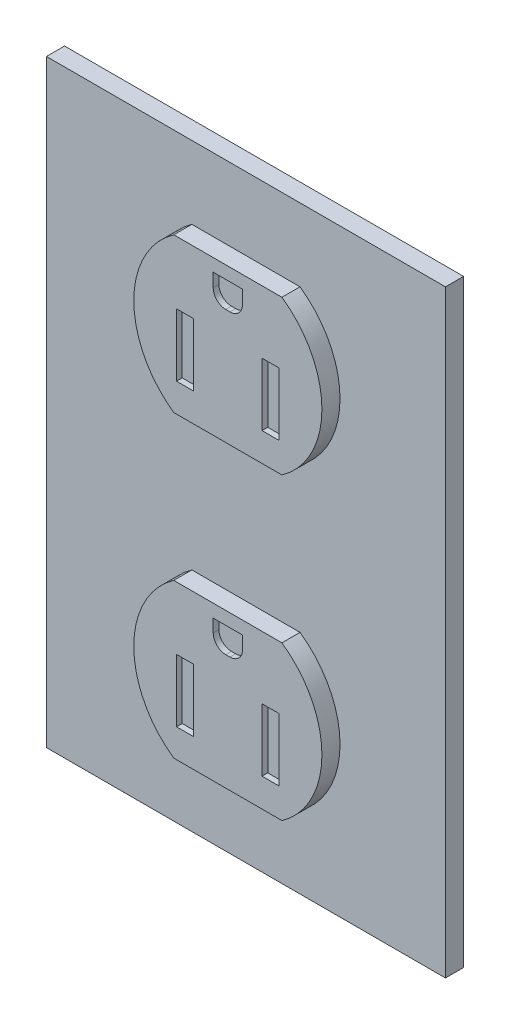
from build123d import *

# Parameters (mm, degrees)
CROQUIS1_W              = 70
CROQUIS1_H              = 105
SALIENTE_EXTRUIR1_DEPTH = 3.175
CROQUIS2_R              = 16.5
SALIENTE_EXTRUIR2_DEPTH = 3.175
CROQUIS3_W              = 26
CROQUIS3_H              = 6
CORTAR_EXTRUIR1_DEPTH   = 3.175
CROQUIS4_W              = 3
CROQUIS4_H              = 11
CORTAR_EXTRUIR2_DEPTH   = 1


with BuildPart() as part:
    # Croquis1 → Saliente-Extruir1 (new body)
    with BuildSketch(Plane.XY):
        with Locations((35, -52.5)):
            Rectangle(CROQUIS1_W, CROQUIS1_H)
    extrude(amount=SALIENTE_EXTRUIR1_DEPTH)

    # Croquis2 → Saliente-Extruir2 (add)
    with BuildSketch(Plane.XY.offset(3.175)):
        with Locations((35, -26.25)):
            Circle(CROQUIS2_R)
        with Locations((35, -78.75)):
            Circle(CROQUIS2_R)
    extrude(amount=SALIENTE_EXTRUIR2_DEPTH)

    # Croquis3 → Cortar-Extruir1 (cut)
    with BuildSketch(Plane.XY.offset(6.35)):
        with Locations((35, -9.75)):
            Rectangle(CROQUIS3_W, CROQUIS3_H)
        with Locations((35, -42.75)):
            Rectangle(CROQUIS3_W, CROQUIS3_H)
        with Locations((35, -62.25)):
            Rectangle(CROQUIS3_W, CROQUIS3_H)
        with Locations((35, -95.25)):
            Rectangle(CROQUIS3_W, CROQUIS3_H)
    extrude(amount=-CORTAR_EXTRUIR1_DEPTH, mode=Mode.SUBTRACT)

    # Croquis4 → Cortar-Extruir2 (cut)
    with BuildSketch(Plane.XY.offset(6.35)):
        with Locations((27.5, -29.25)):
            Rectangle(CROQUIS4_W, CROQUIS4_H)
        with Locations((42.5, -29.25)):
            Rectangle(CROQUIS4_W, CROQUIS4_H)
        with BuildLine():
            Line((34.632057675, -19.532945654), (35.367942325, -19.532945654))
            ThreePointArc((35.367942325, -19.532945654), (36.923577244, -18.888580572), (37.567942325, -17.332945654))
            Line((37.567942325, -17.332945654), (37.567942325, -14.967054346))
            Line((37.567942325, -14.967054346), (32.432057675, -14.967054346))
            Line((32.432057675, -14.967054346), (32.432057675, -17.332945654))
            ThreePointArc((32.432057675, -17.332945654), (33.076422756, -18.888580572), (34.632057675, -19.532945654))
        make_face()
        with Locations((42.5, -81.75)):
            Rectangle(CROQUIS4_W, CROQUIS4_H)
        with Locations((27.5, -81.75)):
            Rectangle(CROQUIS4_W, CROQUIS4_H)
        with BuildLine():
            Line((34.632057675, -71.973579429), (35.367942325, -71.973579429))
            ThreePointArc((35.367942325, -71.973579429), (36.923577244, -71.329214348), (37.567942325, -69.773579429))
            Line((37.567942325, -69.773579429), (37.567942325, -67.526420571))
            Line((37.567942325, -67.526420571), (32.432057675, -67.526420571))
            Line((32.432057675, -67.526420571), (32.432057675, -69.773579429))
            ThreePointArc((32.432057675, -69.773579429), (33.076422756, -71.329214348), (34.632057675, -71.973579429))
        make_face()
    extrude(amount=-CORTAR_EXTRUIR2_DEPTH, mode=Mode.SUBTRACT)


solid = part.part
